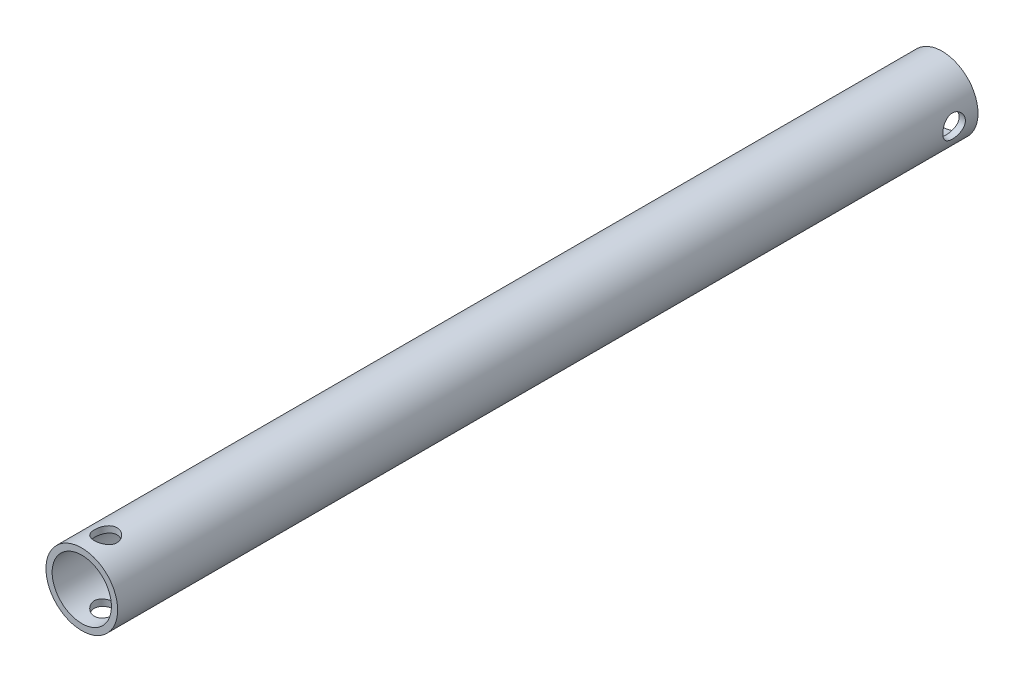
from build123d import *

# Parameters (mm, degrees)
SKETCH1_R           = 9.525
SKETCH1_R_2         = 7.874
BOSS_EXTRUDE1_DEPTH = 228.6
SKETCH2_R           = 3
CUT_EXTRUDE1_DEPTH  = 138.80592
SKETCH3_R           = 3
CUT_EXTRUDE2_DEPTH  = 138.80592


with BuildPart() as part:
    # Sketch1 → Boss-Extrude1 (new body)
    with BuildSketch(Plane.XY):
        Circle(SKETCH1_R)
        Circle(SKETCH1_R_2, mode=Mode.SUBTRACT)
    extrude(amount=BOSS_EXTRUDE1_DEPTH)

    # Sketch2 → Cut-Extrude1 (cut)
    with BuildSketch(Plane(origin=(0, 9.525, 0), x_dir=(1, 0, 0), z_dir=(0, 1, 0))):
        with Locations((0, -222.25)):
            Circle(SKETCH2_R)
    extrude(amount=-CUT_EXTRUDE1_DEPTH, mode=Mode.SUBTRACT)

    # Sketch3 → Cut-Extrude2 (cut)
    with BuildSketch(Plane(origin=(9.525, 0, 0), x_dir=(0, 0, -1), z_dir=(1, 0, 0))):
        with Locations((-6.35, 0)):
            Circle(SKETCH3_R)
    extrude(amount=-CUT_EXTRUDE2_DEPTH, mode=Mode.SUBTRACT)


solid = part.part
